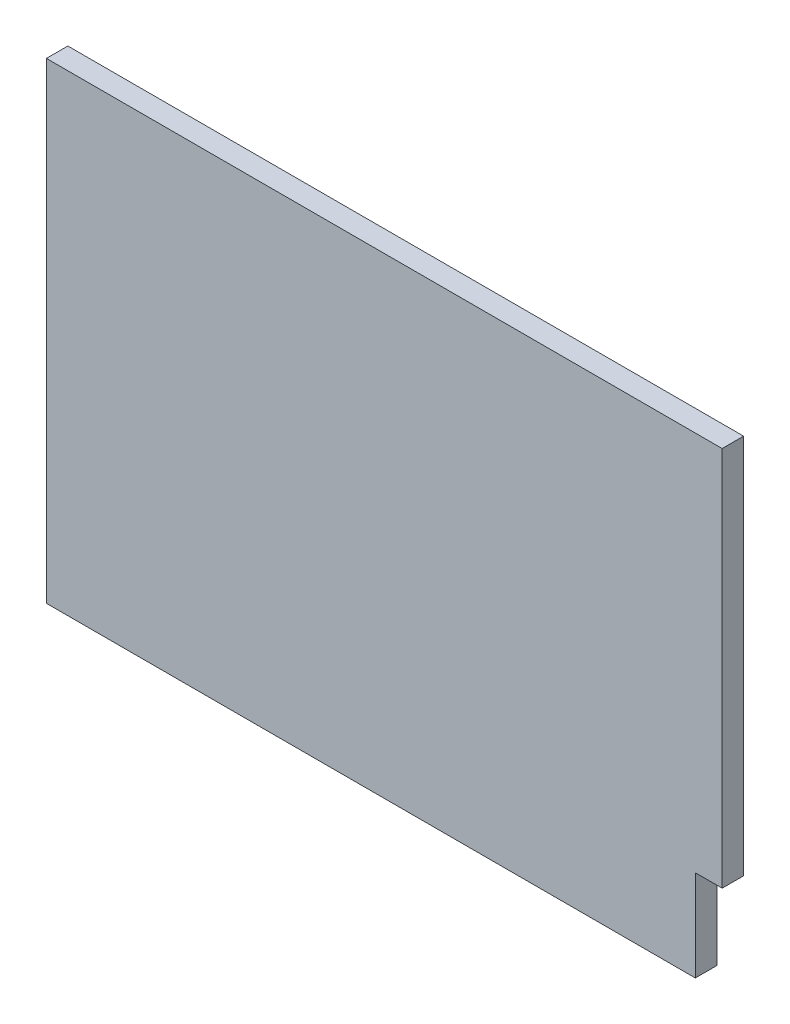
from build123d import *

# Parameters (mm, degrees)
BOSS_EXTRUDE1_DEPTH = 20


with BuildPart() as part:
    # Sketch1 → Boss-Extrude1 (new body)
    with BuildSketch(Plane.XY):
        Polygon((315, -135), (290, -135), (290, -220), (-315, -220), (-315, 220), (315, 220), align=None)
    extrude(amount=BOSS_EXTRUDE1_DEPTH)


solid = part.part
